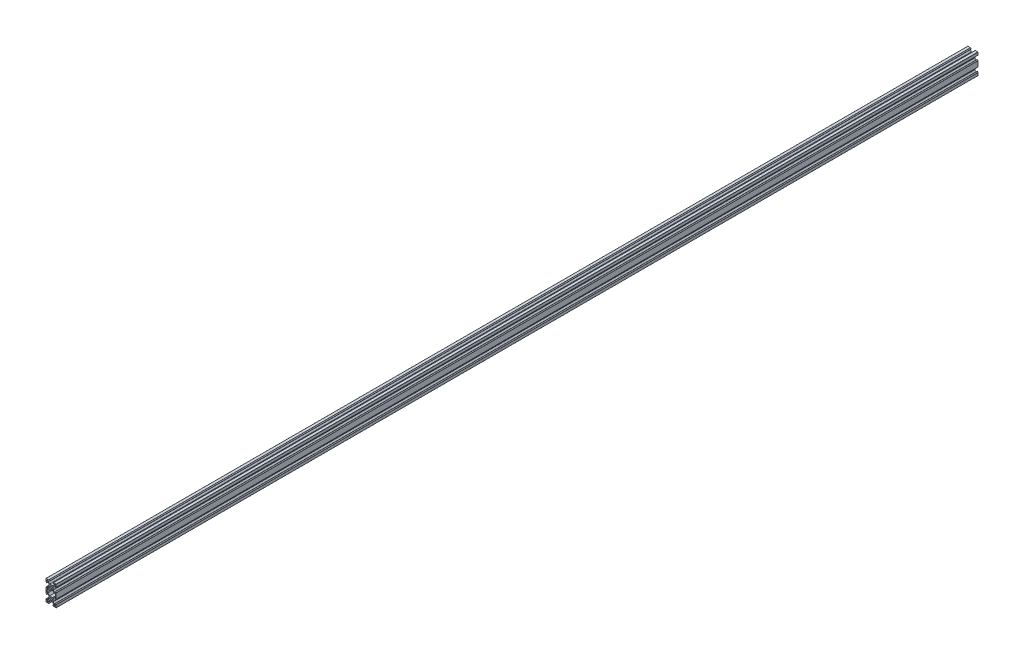
from build123d import *

# Parameters (mm, degrees)
SKETCH1_R            = 2.1
BOSS_EXTRUDE2_DEPTH  = 1800
CUT_EXTRUDE1_DEPTH   = 1801
FILLET1_R            = 0.25
FILLET1_OF_MIRROR1_R = 0.25


with BuildPart() as part:
    # Sketch1 → Boss-Extrude2 (new body)
    with BuildSketch(Plane.XY):
        Polygon((8.199993721, -10), (9.999993721, -10), (9.999993721, -4.63999575), (8.199993721, -2.84), (8.199993721, -5.800653822), (6.861313026, -5.800653822), (3.900652213, -2.84), (3.900652213, 2.84), (6.559993721, 5.499347787), (8.199993721, 5.499347787), (8.199993721, 2.84), (9.999993721, 4.64000425), (9.999993721, 10), (4.63999575, 10), (2.84, 8.2), (5.499325592, 8.2), (5.499325592, 6.56), (2.84, 3.900668129), (-2.84, 3.900668129), (-5.49933815, 6.56), (-5.49933815, 8.2), (-2.84, 8.2), (-4.64000425, 10), (-10.000006279, 10), (-10.000006279, 4.63999575), (-8.200006279, 2.84), (-8.200006279, 5.499347787), (-6.560006279, 5.499347787), (-3.900652213, 2.84), (-3.900652213, -2.84), (-6.861299044, -5.800653822), (-8.200006279, -5.800653822), (-8.200006279, -2.84), (-10.000006279, -4.64000425), (-10.000006279, -10), (-8.200006279, -10), (-8.200006279, -7.300653822), (-6.239977665, -7.300653822), (-2.84, -3.900668129), (2.84, -3.900668129), (6.239993721, -7.300653822), (8.199993721, -7.300653822), align=None)
        Circle(SKETCH1_R, mode=Mode.SUBTRACT)
    boss_extrude2 = extrude(amount=BOSS_EXTRUDE2_DEPTH)

    # Sketch2 → Cut-Extrude1 (cut, through all)
    with BuildSketch(Plane.XY.offset(1800)):
        Polygon((-8.200006279, 6.569347787), (-8.200006279, 8.2), (-6.56933815, 8.2), (-6.56933815, 7.630009211), (-7.62999707, 6.569347787), align=None)
        Polygon((8.199993721, 8.2), (8.199993721, 6.569347787), (7.629987016, 6.569347787), (6.569325592, 7.630006706), (6.569325592, 8.2), align=None)
    cut_extrude1 = extrude(amount=-CUT_EXTRUDE1_DEPTH, mode=Mode.SUBTRACT)

    # Fillet1
    fillet1_edges = [part.edges().sort_by_distance(p)[0] for p in [
        (9.999993721, -4.63999575, 900),
        (-10.000006279, -4.64000425, 900),
        (-8.200006279, -2.84, 900),
        (-8.200006279, 2.84, 900),
        (-10.000006279, 4.63999575, 900),
        (-10.000006279, 10, 900),
        (-4.64000425, 10, 900),
        (-2.84, 8.2, 900),
        (2.84, 8.2, 900),
        (4.63999575, 10, 900),
        (9.999993721, 10, 900),
        (9.999993721, 4.64000425, 900),
        (8.199993721, 2.84, 900),
        (8.199993721, -2.84, 900),
    ]]
    fillet(fillet1_edges, radius=FILLET1_R)

    # Mirror1: Boss-Extrude2 across plane
    add(boss_extrude2.mirror(Plane(origin=(0, -10, 0), x_dir=(0, 0, 1), z_dir=(0, -1, 0))))

    # Fillet1 of Mirror1
    fillet1_of_mirror1_edges = [part.edges().sort_by_distance(p)[0] for p in [
        (9.999993721, -15.36000425, 900),
        (-10.000006279, -15.35999575, 900),
        (-8.200006279, -17.16, 900),
        (-8.200006279, -22.84, 900),
        (-10.000006279, -24.63999575, 900),
        (-10.000006279, -30, 900),
        (-4.64000425, -30, 900),
        (-2.84, -28.2, 900),
        (2.84, -28.2, 900),
        (4.63999575, -30, 900),
        (9.999993721, -30, 900),
        (9.999993721, -24.64000425, 900),
        (8.199993721, -22.84, 900),
        (8.199993721, -17.16, 900),
    ]]
    fillet(fillet1_of_mirror1_edges, radius=FILLET1_OF_MIRROR1_R)

    # Mirror2: Cut-Extrude1 across plane
    add(cut_extrude1.mirror(Plane(origin=(0, -10, 0), x_dir=(0, 0, 1), z_dir=(0, -1, 0))), mode=Mode.SUBTRACT)


solid = part.part
